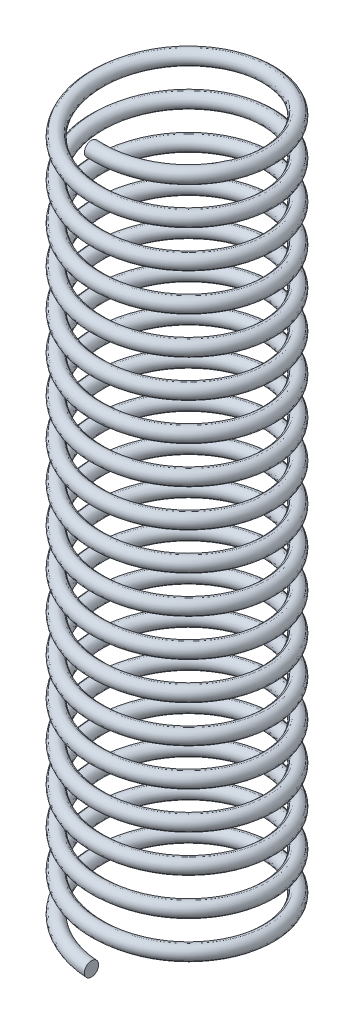
from build123d import *

# Parameters (mm, degrees)
SWEEP1_PITCH  = 1.002631579
SWEEP1_HEIGHT = 19.05
SWEEP1_RADIUS = 2.29235
SKETCH2_R     = 0.1905


with BuildPart() as part:
    # Sweep1: sweep along a helix
    with BuildLine() as sweep1_path:
        Helix(SWEEP1_PITCH, SWEEP1_HEIGHT, SWEEP1_RADIUS, center=(0, 0, 0), direction=(0, 1, 0), lefthand=True)
    # Sketch2 → Sweep1 (sweep)
    with BuildSketch(Plane(origin=(0, 0, 0), x_dir=(0, 0, -1), z_dir=(1, 0, 0))):
        with Locations((-2.29235, 0)):
            Circle(SKETCH2_R)
    sweep(path=sweep1_path.line, is_frenet=True)


solid = part.part
